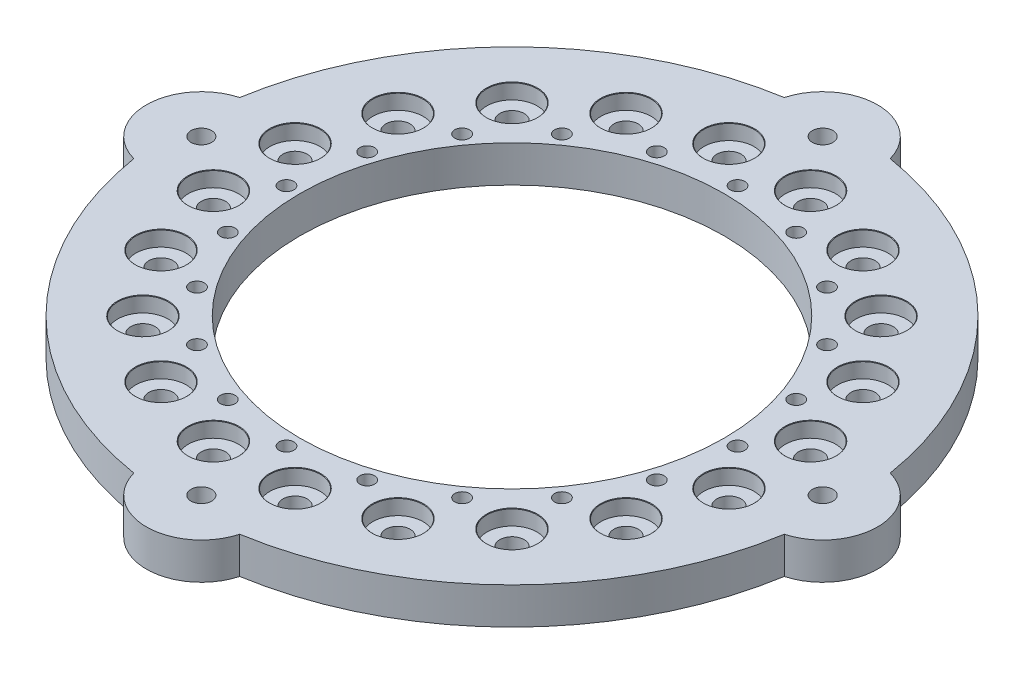
from build123d import *

# Parameters (mm, degrees)
SKETCH3_R                                    = 114.3
SKETCH3_R_2                                  = 73.533
BOSS_EXTRUDE1_DEPTH                          = 12.7
SKETCH16_R                                   = 19.05
BOSS_EXTRUDE2_DEPTH                          = 12.7
CIRPATTERN6_COUNT                            = 4
CIRPATTERN2_COUNT                            = 20
F_1_4_20_TAPPED_HOLE2_D                      = 5.1054
CIRPATTERN4_COUNT                            = 20
CBORE_FOR_1_4_BINDING_HEAD_MACHINE_S_2_COUNT = 2
CBORE_FOR_1_4_BINDING_HEAD_MACHINE_S_2_PITCH = 152.4
CBORE_FOR_1_4_BINDING_HEAD_MACHINE_S_3_COUNT = 2
CBORE_FOR_1_4_BINDING_HEAD_MACHINE_S_3_PITCH = 215.526146906
CBORE_FOR_1_4_BINDING_HEAD_MACHINE_S_4_COUNT = 2
CBORE_FOR_1_4_BINDING_HEAD_MACHINE_S_4_PITCH = 152.4


with BuildPart() as part:
    # Sketch3 → Boss-Extrude1 (new body)
    with BuildSketch(Plane(origin=(0, 0, 0), x_dir=(1, 0, 0), z_dir=(0, 1, 0))):
        Circle(SKETCH3_R)
        Circle(SKETCH3_R_2, mode=Mode.SUBTRACT)
    extrude(amount=BOSS_EXTRUDE1_DEPTH)

    # Sketch16 → Boss-Extrude2 (add)
    with BuildSketch(Plane(origin=(0, 12.7, 0), x_dir=(1, 0, 0), z_dir=(0, 1, 0))):
        with Locations((107.763073453, 0)):
            Circle(SKETCH16_R)
    boss_extrude2 = extrude(amount=-BOSS_EXTRUDE2_DEPTH)

    # CirPattern6: Boss-Extrude2 ×4 about axis
    cirpattern6_axis = Axis((0, 12.7, 0), (0, -1, 0))
    for i in range(1, CIRPATTERN6_COUNT):
        add(boss_extrude2.rotate(cirpattern6_axis, i * 360 / CIRPATTERN6_COUNT))

    # Sketch8 → CBORE for 5_16 Binding Head Machine Scre (revolve, cut)
    with BuildSketch(Plane(origin=(89.411079645, 12.7, -14.161323808), x_dir=(0, 0, 1), z_dir=(1, 0, 0))):
        Polygon((0, 0), (0, 12.7), (4.2164, 12.7), (4.2164, 5.3086), (8.73125, 5.3086), (8.73125, 0.15875), (8.89, 0), align=None)
    cbore_for_5_16_binding_head_machine_scre = revolve(axis=Axis((89.411079645, 19.05, -14.161323808), (0, -1, 0)), mode=Mode.SUBTRACT)

    # CirPattern2: CBORE for 5_16 Binding Head Machine Scre ×20 about axis
    cirpattern2_axis = Axis((0, 12.7, 0), (0, -1, 0))
    for i in range(1, CIRPATTERN2_COUNT):
        add(cbore_for_5_16_binding_head_machine_scre.rotate(cirpattern2_axis, i * 360 / CIRPATTERN2_COUNT), mode=Mode.SUBTRACT)

    # 1_4-20 Tapped Hole2 (through all)
    with Locations(Plane(origin=(0, 12.7, 0), x_dir=(1, 0, 0), z_dir=(0, 1, 0))):
        with Locations((78.232, 0)):
            f_1_4_20_tapped_hole2 = Hole(F_1_4_20_TAPPED_HOLE2_D / 2)

    # CirPattern4: 1_4-20 Tapped Hole2 ×20 about axis
    cirpattern4_axis = Axis((0, 12.7, 0), (0, -1, 0))
    for i in range(1, CIRPATTERN4_COUNT):
        add(f_1_4_20_tapped_hole2.rotate(cirpattern4_axis, i * 360 / CIRPATTERN4_COUNT), mode=Mode.SUBTRACT)

    # Sketch19 → CBORE for 1_4 Binding Head Machine Screw (revolve, cut)
    with BuildSketch(Plane(origin=(0, 0, 107.763073453), x_dir=(0, 0, -1), z_dir=(1, 0, 0))):
        Polygon((0, 0), (0, 12.7), (3.57124, 12.7), (3.57124, 4.191), (7.14375, 4.191), (7.14375, 0.635), (7.77875, 0), align=None)
    cbore_for_1_4_binding_head_machine_screw = revolve(axis=Axis((0, -6.35, 107.763073453), (0, 1, 0)), mode=Mode.SUBTRACT)

    # CBORE for 1_4 Binding Head Machine S 2: CBORE for 1_4 Binding Head Machine Screw ×2
    with Locations(*[Vector(0.7071067811865476, 0, -0.7071067811865475) * (i * CBORE_FOR_1_4_BINDING_HEAD_MACHINE_S_2_PITCH) for i in range(1, CBORE_FOR_1_4_BINDING_HEAD_MACHINE_S_2_COUNT)]):
        add(cbore_for_1_4_binding_head_machine_screw, mode=Mode.SUBTRACT)

    # CBORE for 1_4 Binding Head Machine S 3: CBORE for 1_4 Binding Head Machine Screw ×2
    with Locations(*[(0, 0, -i * CBORE_FOR_1_4_BINDING_HEAD_MACHINE_S_3_PITCH) for i in range(1, CBORE_FOR_1_4_BINDING_HEAD_MACHINE_S_3_COUNT)]):
        add(cbore_for_1_4_binding_head_machine_screw, mode=Mode.SUBTRACT)

    # CBORE for 1_4 Binding Head Machine S 4: CBORE for 1_4 Binding Head Machine Screw ×2
    with Locations(*[Vector(-0.7071067811865475, 0, -0.7071067811865477) * (i * CBORE_FOR_1_4_BINDING_HEAD_MACHINE_S_4_PITCH) for i in range(1, CBORE_FOR_1_4_BINDING_HEAD_MACHINE_S_4_COUNT)]):
        add(cbore_for_1_4_binding_head_machine_screw, mode=Mode.SUBTRACT)


solid = part.part
